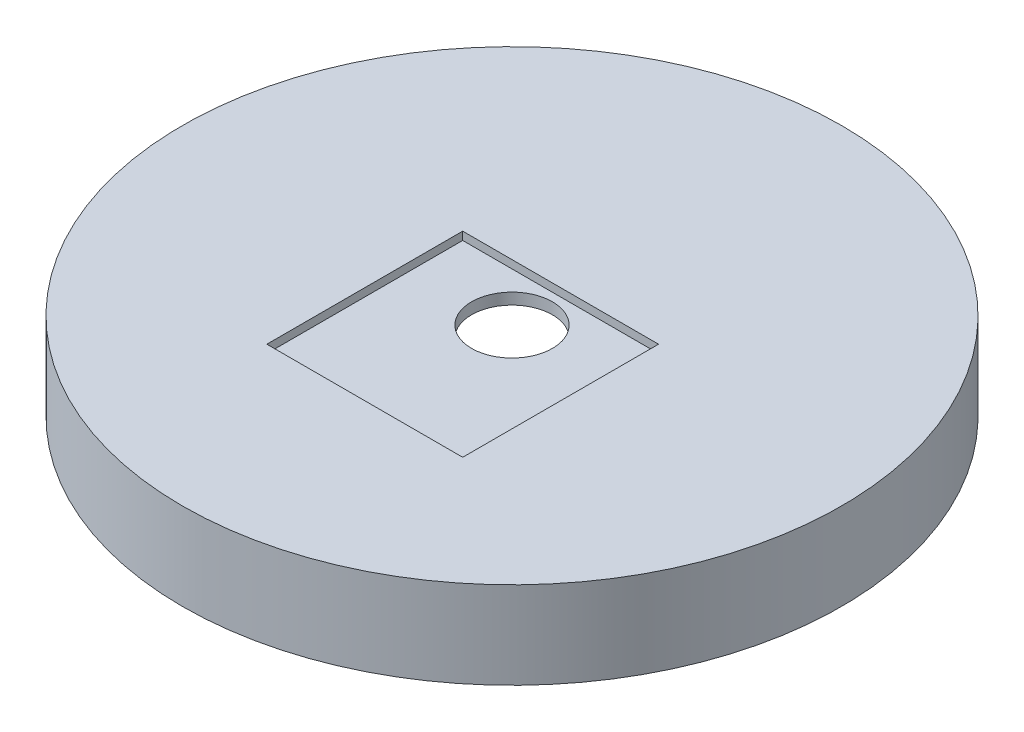
from build123d import *

# Parameters (mm, degrees)
SKETCH5_W          = 15.748
SKETCH5_H          = 15.748
CUT_EXTRUDE1_DEPTH = 6.35


with BuildPart() as part:
    # Sketch3 → Revolve1 (revolve)
    with BuildSketch(Plane.XY):
        Polygon((22, 0), (3.25, 5.442857143), (3.25, 7), (26.5, 7), (26.5, 0), align=None)
    revolve(axis=Axis((0, 0, 0), (0, -1, 0)))

    # Sketch5 → Cut-Extrude1 (cut)
    with BuildSketch(Plane(origin=(0, 12.7, 0), x_dir=(1, 0, 0), z_dir=(0, 1, 0))):
        with Locations((0, -3.964)):
            Rectangle(SKETCH5_W, SKETCH5_H)
    extrude(amount=-CUT_EXTRUDE1_DEPTH, mode=Mode.SUBTRACT)


solid = part.part
